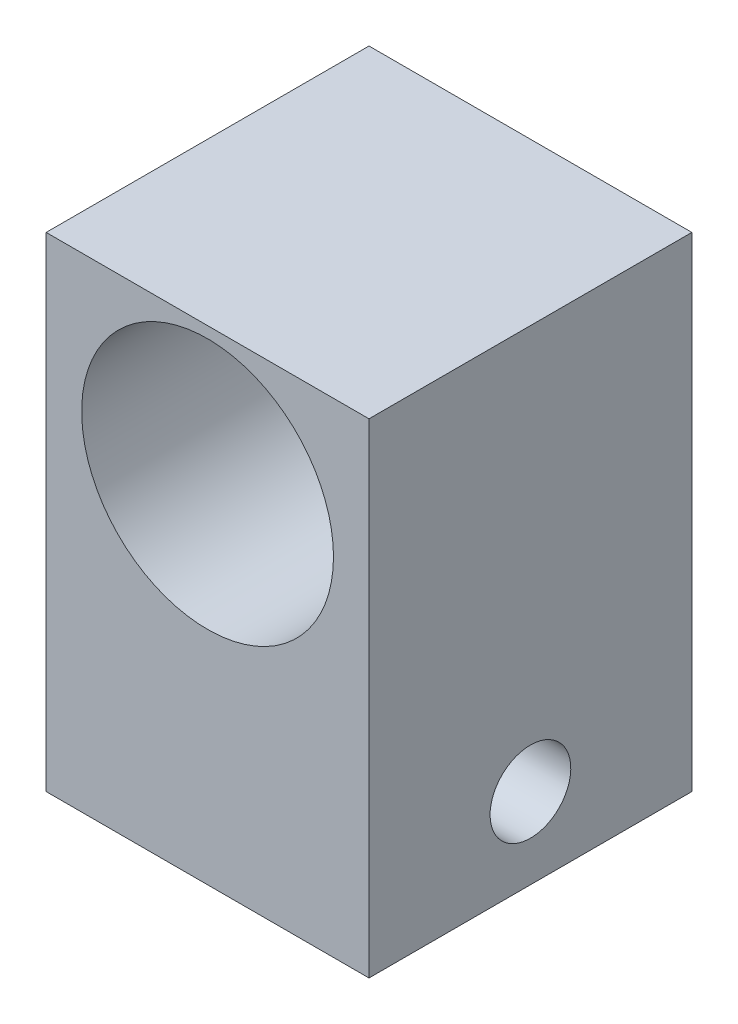
from build123d import *

# Parameters (mm, degrees)
SKETCH1_W           = 50.8
SKETCH1_H           = 76.2
BOSS_EXTRUDE1_DEPTH = 50.8
SKETCH2_R           = 19.812
CUT_EXTRUDE1_DEPTH  = 51.8
SKETCH3_R           = 6.35
CUT_EXTRUDE2_DEPTH  = 51.8


with BuildPart() as part:
    # Sketch1 → Boss-Extrude1 (new body)
    with BuildSketch(Plane.XY):
        Rectangle(SKETCH1_W, SKETCH1_H)
    extrude(amount=BOSS_EXTRUDE1_DEPTH)

    # Sketch2 → Cut-Extrude1 (cut, through all)
    with BuildSketch(Plane.XY.offset(50.8)):
        with Locations((0, 16.51)):
            Circle(SKETCH2_R)
    extrude(amount=-CUT_EXTRUDE1_DEPTH, mode=Mode.SUBTRACT)

    # Sketch3 → Cut-Extrude2 (cut, through all)
    with BuildSketch(Plane(origin=(25.4, 0, 0), x_dir=(0, 0, -1), z_dir=(1, 0, 0))):
        with Locations((-25.4, -25.4)):
            Circle(SKETCH3_R)
    extrude(amount=-CUT_EXTRUDE2_DEPTH, mode=Mode.SUBTRACT)


solid = part.part
